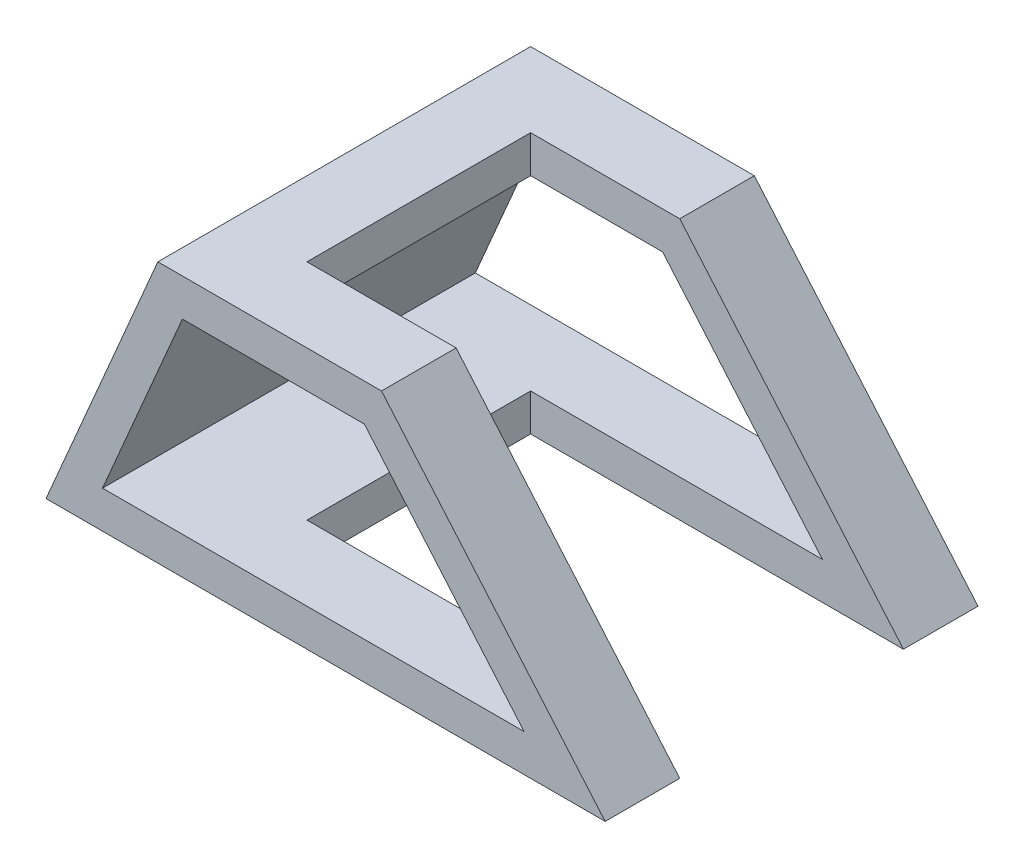
from build123d import *

# Parameters (mm, degrees)
EXTRU_MINCE5_DEPTH      = 100
ESQUISSE8_W             = 100
ESQUISSE8_H             = 60
ENL_V_MAT_EXTRU_4_DEPTH = 71


with BuildPart() as part:
    # Esquisse4 → Extru.-Mince5 (new body)
    with BuildSketch(Plane.XY):
        Polygon((150, 0), (90, 70), (30, 70), (0, 0), (30, 0), (90, 0), align=None)
        Polygon((128.257793632, 10), (85.400650775, 60), (36.59396158, 60), (15.165390151, 10), (30, 10), (90, 10), align=None, mode=Mode.SUBTRACT)
    extrude(amount=-EXTRU_MINCE5_DEPTH)

    # Esquisse8 → Enlèv. mat.-Extru.4 (cut, through all)
    with BuildSketch(Plane(origin=(0, 70, 0), x_dir=(1, 0, 0), z_dir=(0, 1, 0))):
        with Locations((100, 50)):
            Rectangle(ESQUISSE8_W, ESQUISSE8_H)
    extrude(amount=-ENL_V_MAT_EXTRU_4_DEPTH, mode=Mode.SUBTRACT)


solid = part.part
